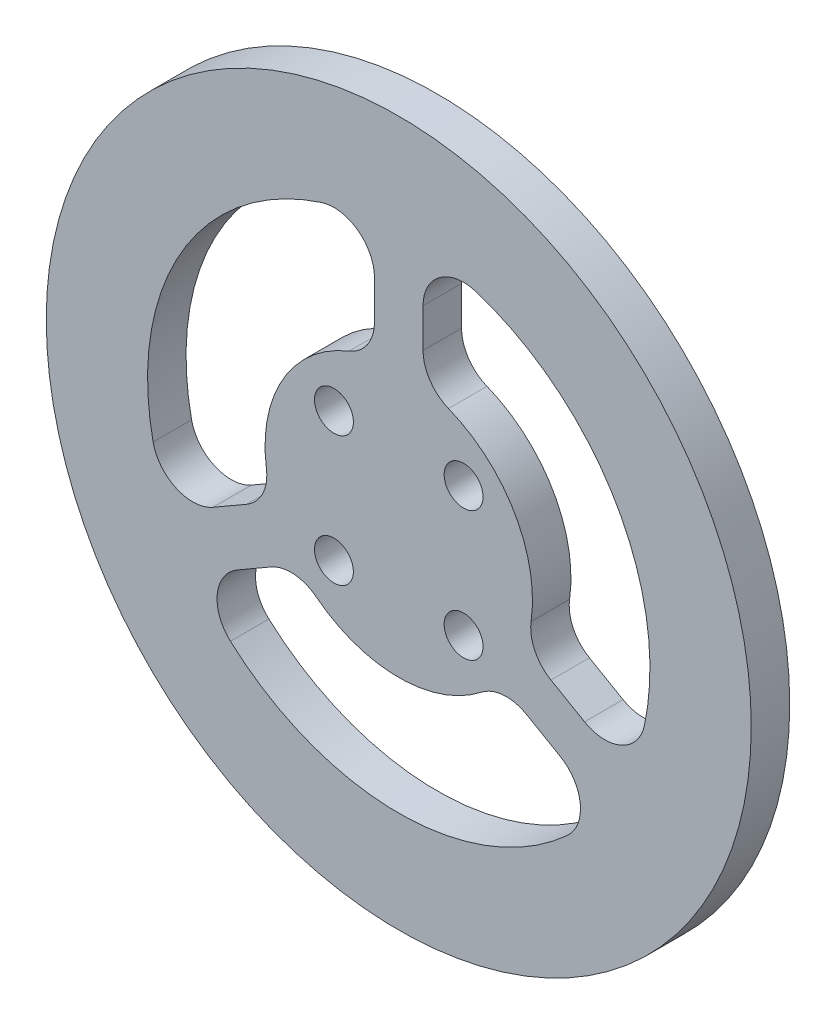
from build123d import *

# Parameters (mm, degrees)
SKETCH1_R            = 43.5
BOSS_EXTRUDE1_DEPTH  = 4.7498
SKETCH2_R            = 31
SKETCH2_R_2          = 16.5
CUT_EXTRUDE1_DEPTH   = 21.73
BOSS_EXTRUDE2_DEPTH  = 4.7498
CIRPATTERN1_COUNT    = 3
FILLET1_R            = 5
M4_CLEARANCE_HOLE1_D = 4.8


with BuildPart() as part:
    # Sketch1 → Boss-Extrude1 (new body)
    with BuildSketch(Plane.XY):
        Circle(SKETCH1_R)
    extrude(amount=BOSS_EXTRUDE1_DEPTH)

    # Sketch2 → Cut-Extrude1 (cut)
    with BuildSketch(Plane.XY.offset(4.7498)):
        Circle(SKETCH2_R)
        Circle(SKETCH2_R_2, mode=Mode.SUBTRACT)
    extrude(amount=-CUT_EXTRUDE1_DEPTH, mode=Mode.SUBTRACT)

    # Sketch3 → Boss-Extrude2 (add)
    with BuildSketch(Plane.XY.offset(4.7498)):
        with BuildLine():
            Line((-3, 16.22498074), (-3, 30.854497241))
            ThreePointArc((-3, 30.854497241), (0, 31), (3, 30.854497241))
            Line((3, 30.854497241), (3, 16.22498074))
            ThreePointArc((3, 16.22498074), (0, 16.5), (-3, 16.22498074))
        make_face()
    boss_extrude2 = extrude(amount=-BOSS_EXTRUDE2_DEPTH)

    # CirPattern1: Boss-Extrude2 ×3 about axis
    cirpattern1_axis = Axis((0, 0, 0), (0, 0, 1))
    for i in range(1, CIRPATTERN1_COUNT):
        add(boss_extrude2.rotate(cirpattern1_axis, i * 360 / CIRPATTERN1_COUNT))

    # Fillet1
    fillet1_edges = [part.edges().sort_by_distance(p)[0] for p in [
        (-15.551245496, -5.514414158, 2.3749),
        (-12.551245496, -10.710566581, 2.3749),
        (-25.220778432, -18.025324832, 2.3749),
        (-28.220778432, -12.829172409, 2.3749),
        (12.551245496, -10.710566581, 2.3749),
        (15.551245496, -5.514414158, 2.3749),
        (28.220778432, -12.829172409, 2.3749),
        (25.220778432, -18.025324832, 2.3749),
        (3, 16.22498074, 2.3749),
        (-3, 16.22498074, 2.3749),
        (-3, 30.854497241, 2.3749),
        (3, 30.854497241, 2.3749),
    ]]
    fillet(fillet1_edges, radius=FILLET1_R)

    # M4 Clearance Hole1 (through all)
    with Locations(Plane.XY.offset(4.7498)):
        with Locations((-8, 8), (-8, -8), (8, -8), (8, 8)):
            Hole(M4_CLEARANCE_HOLE1_D / 2)


solid = part.part
